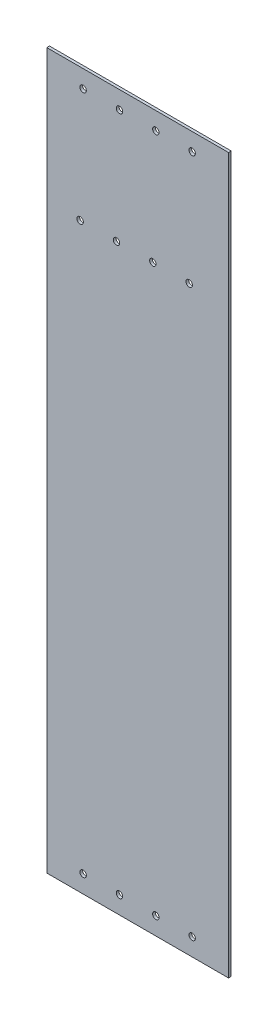
from build123d import *

# Parameters (mm, degrees)
SKETCH1_W            = 155
SKETCH1_H            = 609.6
BOSS_EXTRUDE1_DEPTH  = 2.305
M5_CLEARANCE_HOLE1_D = 5.5
SKETCH4_R            = 2.75
CUT_EXTRUDE1_DEPTH   = 3.305
LPATTERN2_COUNT      = 4
LPATTERN2_PITCH      = 31


with BuildPart() as part:
    # Sketch1 → Boss-Extrude1 (new body)
    with BuildSketch(Plane.XY):
        Rectangle(SKETCH1_W, SKETCH1_H)
    extrude(amount=BOSS_EXTRUDE1_DEPTH)

    # M5 Clearance Hole1 (through all)
    with Locations(Plane.XY.offset(2.305)):
        with Locations((-46.5, 289.795), (-15.5, 289.795), (15.5, 289.795), (46.5, 289.795), (-46.5, -289.795), (-15.5, -289.795), (15.5, -289.795), (46.5, -289.795)):
            Hole(M5_CLEARANCE_HOLE1_D / 2)

    # Sketch4 → Cut-Extrude1 (cut, through all)
    with BuildSketch(Plane.XY.offset(2.305)):
        with Locations((-49.04, 191.395)):
            Circle(SKETCH4_R)
    cut_extrude1 = extrude(amount=-CUT_EXTRUDE1_DEPTH, mode=Mode.SUBTRACT)

    # LPattern2: Cut-Extrude1 ×4
    with Locations(*[(i * LPATTERN2_PITCH, 0, 0) for i in range(1, LPATTERN2_COUNT)]):
        add(cut_extrude1, mode=Mode.SUBTRACT)


solid = part.part
